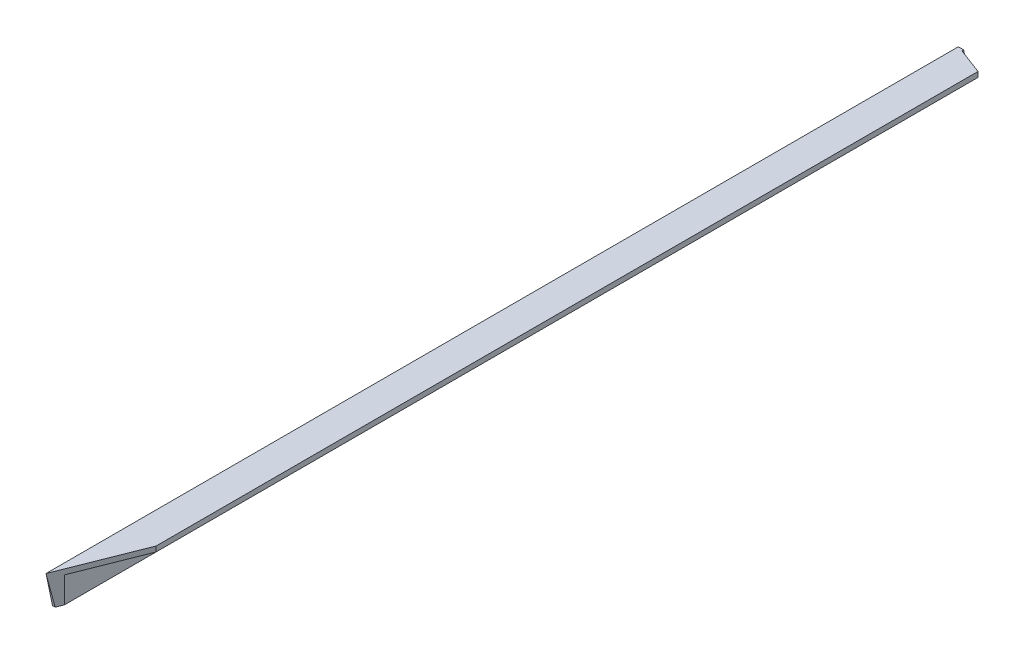
from build123d import *

# Parameters (mm, degrees)
BOSS_EXTRUDE1_DEPTH = 1143
Y_FACE_DEPTH        = 39.1
X_FACE_DEPTH        = 39.1


with BuildPart() as part:
    # Sketch2 → Boss-Extrude1 (new body)
    with BuildSketch(Plane.XY):
        Polygon((0, 0), (0, -38.1), (6.35, -38.1), (6.35, -6.35), (38.1, -6.35), (38.1, 0), align=None)
    extrude(amount=BOSS_EXTRUDE1_DEPTH)

    # Sketch3 → Y Face (cut, through all)
    with BuildSketch(Plane(origin=(0, 0, 0), x_dir=(1, 0, 0), z_dir=(0, 1, 0))):
        Polygon((6.35, 0), (6.35, -31.75), (38.1, -43.790982062), (38.1, 0), align=None)
        Polygon((38.1, -1046.772380605), (0, -1143), (38.1, -1143), align=None)
    extrude(amount=-Y_FACE_DEPTH, mode=Mode.SUBTRACT)

    # Sketch4 → X Face (cut, through all)
    with BuildSketch(Plane.ZY):
        Polygon((1143, 0), (1135.00664554, -38.1), (1143, -38.1), align=None)
        Polygon((0, -38.1), (21.672171987, -38.1), (29.665526448, 0), (0, 0), align=None)
    extrude(amount=-X_FACE_DEPTH, mode=Mode.SUBTRACT)


solid = part.part
